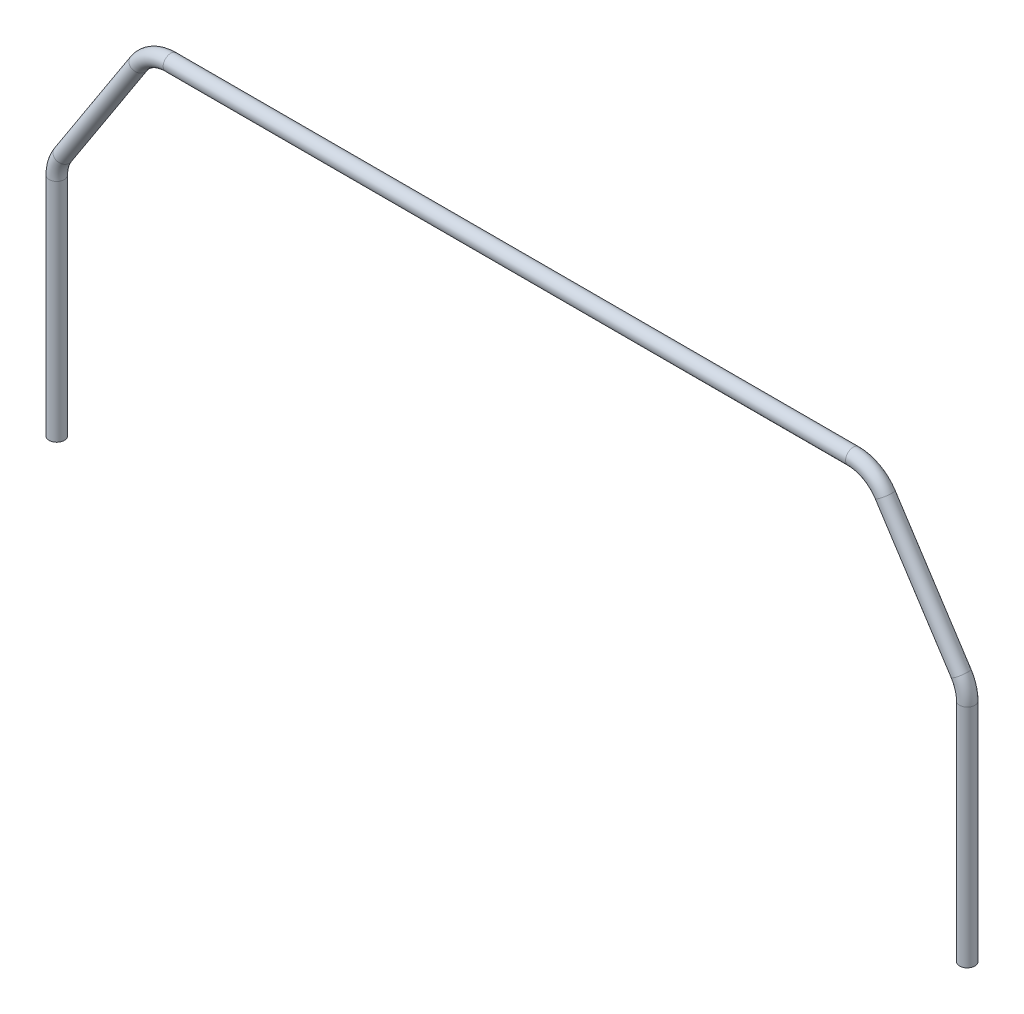
from build123d import *

# Parameters (mm, degrees)
SWEEP2_PROFILE_R = 2


with BuildPart() as part:
    # Sweep2: sweep along a path in Sketch6
    with BuildLine(Plane.XY) as sweep2_path:
        Line((-119.5, -10), (-119.5, 49.293266116))
        ThreePointArc((-119.5, 49.293266116), (-119.088526749, 52.132307288), (-117.887969044, 54.737710561))
        Line((-117.887969044, 54.737710561), (-97.956909951, 85.444444444))
        ThreePointArc((-97.956909951, 85.444444444), (-94.341547928, 88.787617551), (-89.568940906, 90))
        Line((-89.568940906, 90), (89.568940906, 90))
        ThreePointArc((89.568940906, 90), (94.341547928, 88.787617551), (97.956909951, 85.444444444))
        Line((97.956909951, 85.444444444), (117.887969044, 54.737710561))
        ThreePointArc((117.887969044, 54.737710561), (119.088526749, 52.132307288), (119.5, 49.293266116))
        Line((119.5, 49.293266116), (119.5, -10))
    # Sweep2 profile (on start of the path) → Sweep2 (sweep)
    with BuildSketch(Plane(origin=(-119.5, -10, 0), x_dir=(0, 0, 1), z_dir=(0, 1, 0))):
        Circle(SWEEP2_PROFILE_R)
    sweep(path=sweep2_path.line)


solid = part.part
